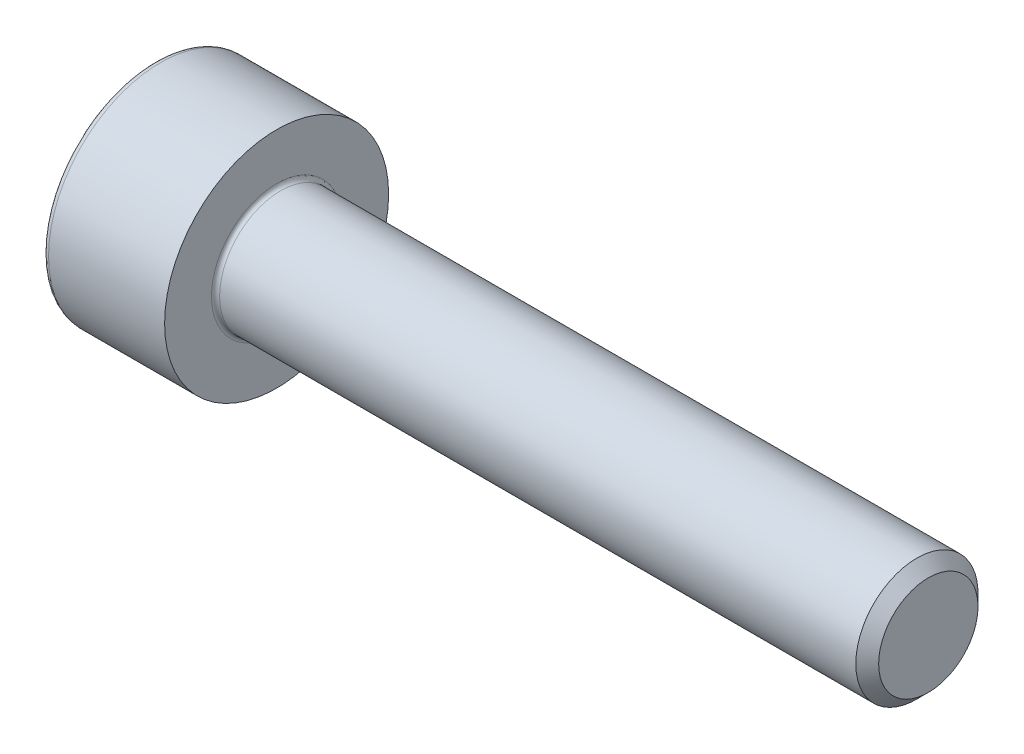
from build123d import *

# Parameters (mm, degrees)
FILLET1_R   = 0.1
FILLET2_R   = 0.15
HEX_2_DEPTH = 1.3


with BuildPart() as part:
    # BodySke → Base-Revolve (revolve)
    with BuildSketch(Plane.XY, mode=Mode.PRIVATE) as base_revolve_sk:
        Polygon((0, 0), (0, 2.75), (3, 2.75), (3, 1.5), (18.7195, 1.5), (19, 1.2195), (19, 0), align=None)
    revolve(base_revolve_sk.sketch.rotate(Axis((-31.75, 0, 0), (1, 0, 0)), 90), axis=Axis((-31.75, 0, 0), (1, 0, 0)))  # turned: the seam where the file's is

    # Fillet1
    fillet1_edges = [part.edges().sort_by_distance(p)[0] for p in [
        (3, 0, -1.5),
    ]]
    fillet(fillet1_edges, radius=FILLET1_R)

    # Fillet2
    fillet2_edges = [part.edges().sort_by_distance(p)[0] for p in [
        (0, 0, -2.75),
    ]]
    fillet(fillet2_edges, radius=FILLET2_R)

    # Sketch2 → Hex-PreBroach (revolve, cut)
    with BuildSketch(Plane.XY, mode=Mode.PRIVATE) as hex_prebroach_sk:
        Polygon((0, 1.28), (1.3, 1.28), (2.039008345, 0), (0, 0), align=None)
    revolve(hex_prebroach_sk.sketch.rotate(Axis((0, 0, 0), (1, 0, 0)), 90), axis=Axis((0, 0, 0), (1, 0, 0)), mode=Mode.SUBTRACT)  # turned: the seam where the file's is

    # Sketch3 → Hex 2 (cut)
    with BuildSketch(Plane(origin=(0, 0, 0), x_dir=(0, 0.5, 0.866025404), z_dir=(-1, 0, 0))):
        Polygon((0.739008345, 1.28), (-0.739008345, 1.28), (-1.478016689, 0), (-0.739008345, -1.28), (0.739008345, -1.28), (1.478016689, 0), align=None)
    extrude(amount=-HEX_2_DEPTH, mode=Mode.SUBTRACT)


solid = part.part
